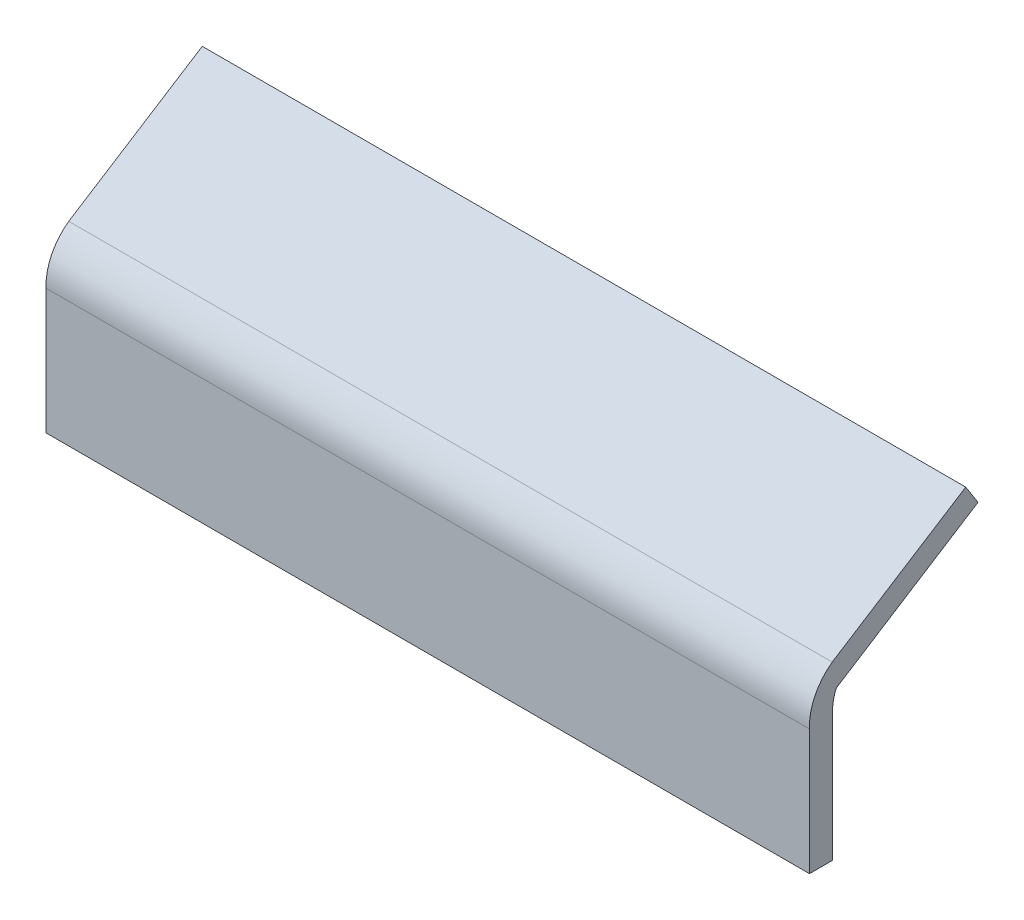
from build123d import *

# Parameters (mm, degrees)
SKETCH1_W           = 1115
SKETCH1_H           = 183
BOSS_EXTRUDE1_DEPTH = 33.45
BOSS_EXTRUDE2_DEPTH = 1115


with BuildPart() as part:
    # Sketch1 → Boss-Extrude1 (new body)
    with BuildSketch(Plane.XY):
        Rectangle(SKETCH1_W, SKETCH1_H)
    extrude(amount=BOSS_EXTRUDE1_DEPTH)

    # Sketch2 → Boss-Extrude2 (add)
    with BuildSketch(Plane(origin=(557.5, 0, 0), x_dir=(0, 0, -1), z_dir=(1, 0, 0))):
        with BuildLine():
            Line((-0.236252667, 159.515154012), (194.779142231, 283.329514055))
            Line((194.779142231, 283.329514055), (212.708104756, 255.090271807))
            Line((212.708104756, 255.090271807), (8.204240057, 125.251726766))
            ThreePointArc((8.204240057, 125.251726766), (5.689681252, 122.973302793), (4.081808438, 119.985165113))
            ThreePointArc((4.081808438, 119.985165113), (0.749606072, 105.927620335), (0, 91.5))
            Line((0, 91.5), (-33.45, 91.5))
            ThreePointArc((-33.45, 91.5), (-25.395939678, 129.684160674), (-0.236252667, 159.515154012))
        make_face()
    extrude(amount=-BOSS_EXTRUDE2_DEPTH)


solid = part.part
